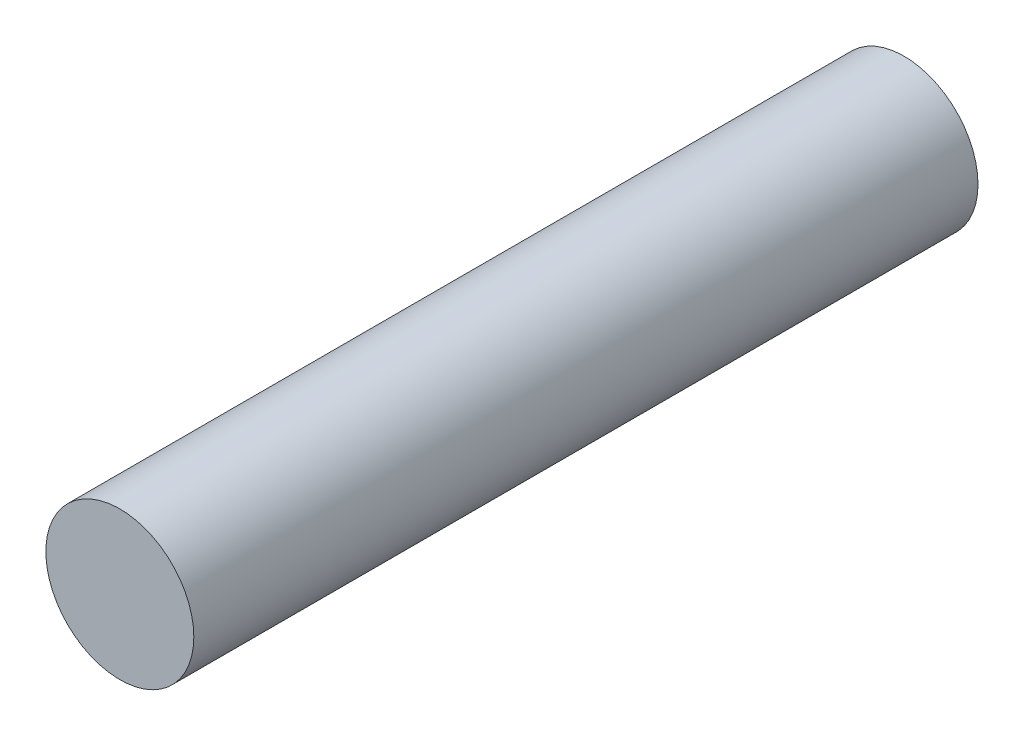
from build123d import *

# Parameters (mm, degrees)
SKETCH1_R      = 2
EXTRUDE1_DEPTH = 21.2


with BuildPart() as part:
    # Sketch1 → Extrude1 (new body)
    with BuildSketch(Plane.XY):
        Circle(SKETCH1_R)
    extrude(amount=-EXTRUDE1_DEPTH)


solid = part.part
